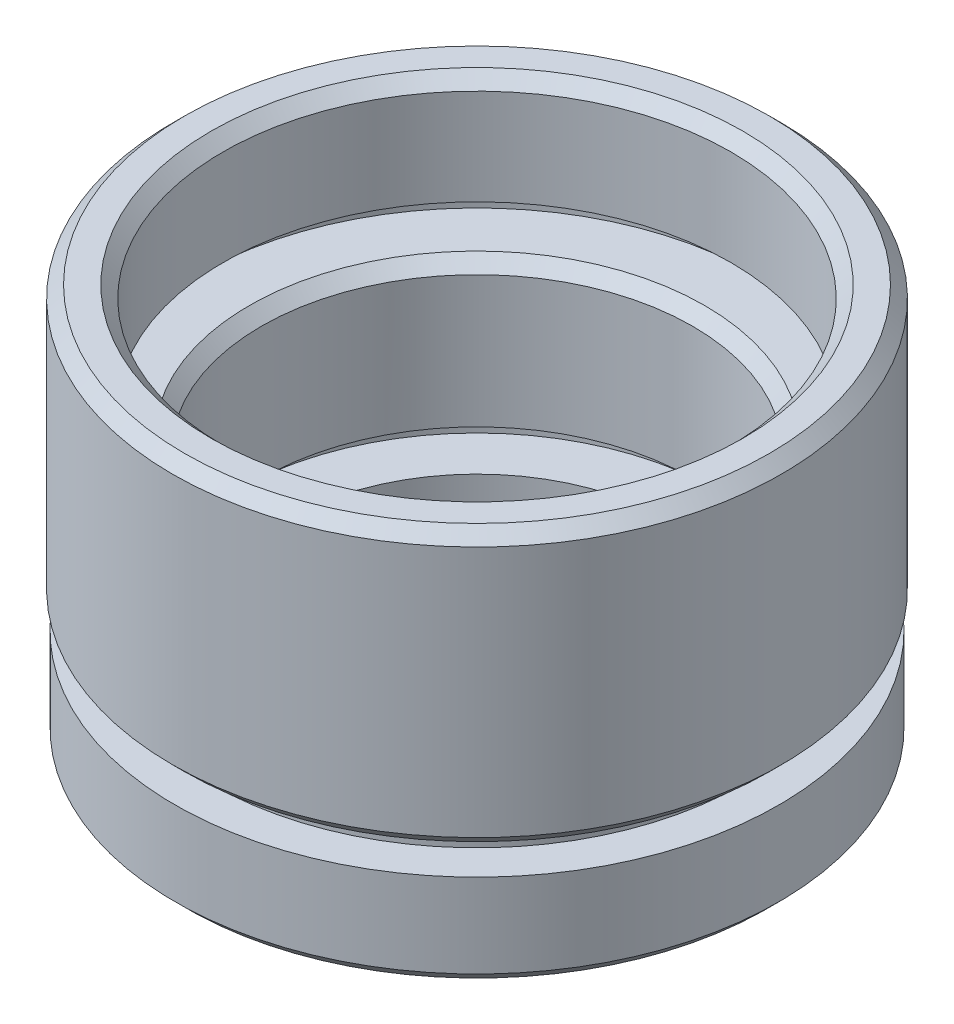
from build123d import *

# Parameters (mm, degrees)
CHAMFER_1_SIZE = 0.5


with BuildPart() as part:
    # 草图1 → 旋转1 (revolve)
    with BuildSketch(Plane.XY, mode=Mode.PRIVATE) as revolve_1_sk:
        Polygon((7.25, 0), (7.25, 2), (8, 2), (8, 4), (10.1, 4), (10.1, 5), (9, 5), (9, 11), (11.7, 11), (11.7, 12), (10.6, 12), (10.6, 16.5), (12.2, 16.5), (12.7, 16), (12.7, 5.5), (12.2, 5), (11.1, 5), (11.1, 4), (12.6, 4), (12.6, 0.5), (12.1, 0), align=None)
    revolve(revolve_1_sk.sketch.rotate(Axis((0, 0, 0), (0, 1, 0)), 90), axis=Axis((0, 0, 0), (0, 1, 0)))  # turned: the seam where the file's is

    # 倒角1
    chamfer_1_edges = [part.edges().sort_by_distance(p)[0] for p in [
        (0, 11, 9),
        (0, 16.5, 10.6),
    ]]
    chamfer(chamfer_1_edges, length=CHAMFER_1_SIZE)


solid = part.part
